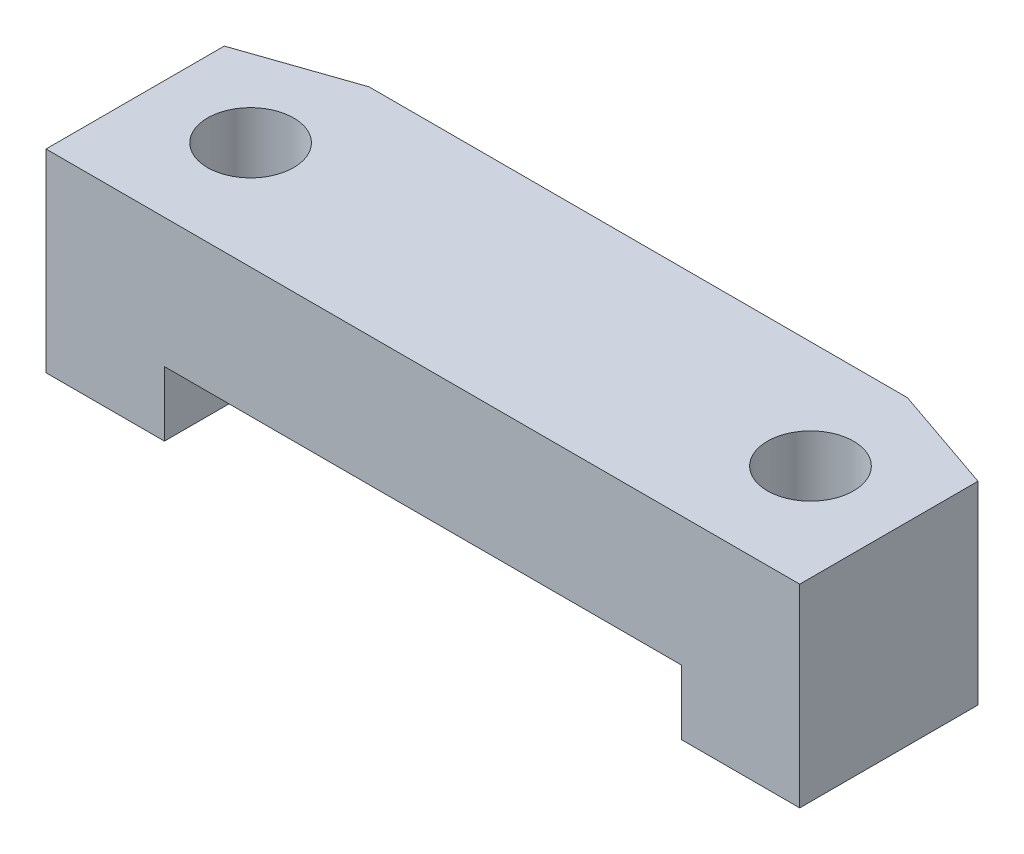
from build123d import *

# Parameters (mm, degrees)
SKETCH_1_W          = 17.5
SKETCH_1_H          = 4.5
EXTRUDE_1_DEPTH     = 5
SKETCH_2_R          = 1
CUT_EXTRUDE_1_DEPTH = 5.5
SKETCH_3_W          = 12
SKETCH_3_H          = 1.5
CUT_EXTRUDE_3_DEPTH = 6
CHAMFER_2_SIZE      = 2.5
CHAMFER_2_SIZE2     = 0.860819033


with BuildPart() as part:
    # Эскиз1 → Бобышка-Вытянуть1 (new body)
    with BuildSketch(Plane.XY):
        with Locations((8.75, 2.25)):
            Rectangle(SKETCH_1_W, SKETCH_1_H)
    extrude(amount=EXTRUDE_1_DEPTH)

    # Эскиз2 → Вырез-Вытянуть1 (cut, through all)
    with BuildSketch(Plane(origin=(0, 4.5, 0), x_dir=(1, 0, 0), z_dir=(0, 1, 0))):
        with Locations((2.25, -2.5)):
            Circle(SKETCH_2_R)
        with Locations((15.25, -2.5)):
            Circle(SKETCH_2_R)
    extrude(amount=-CUT_EXTRUDE_1_DEPTH, mode=Mode.SUBTRACT)

    # Эскиз3 → Вырез-Вытянуть3 (cut, through all)
    with BuildSketch(Plane.XY.offset(5)):
        with Locations((8.75, 0.75)):
            Rectangle(SKETCH_3_W, SKETCH_3_H)
    extrude(amount=-CUT_EXTRUDE_3_DEPTH, mode=Mode.SUBTRACT)

    # Фаска2
    chamfer_2_edges = [part.edges().sort_by_distance(p)[0] for p in [
        (17.5, 2.25, 0),
        (0, 2.25, 0),
    ]]
    chamfer_2_side = [part.faces().sort_by_distance(p)[0] for p in [
        (8.75, 2.694444444, 0),
    ]]
    chamfer(chamfer_2_edges, length=CHAMFER_2_SIZE, length2=CHAMFER_2_SIZE2, reference=chamfer_2_side[0])


solid = part.part
